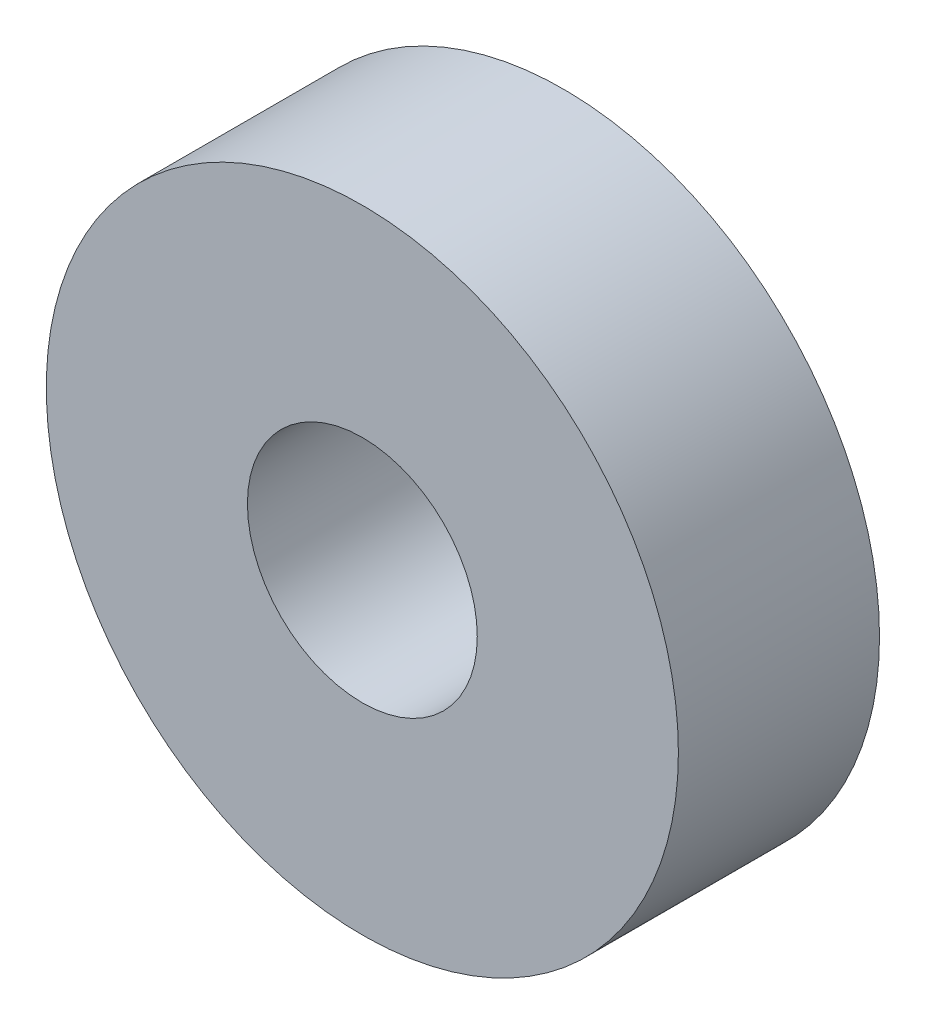
from build123d import *

# Parameters (mm, degrees)
ESQUISSE1_R      = 11
ESQUISSE1_R_2    = 4
EXTRUSION1_DEPTH = 7


with BuildPart() as part:
    # Esquisse1 → Extrusion1 (new body)
    with BuildSketch(Plane.XY):
        Circle(ESQUISSE1_R)
        Circle(ESQUISSE1_R_2, mode=Mode.SUBTRACT)
    extrude(amount=EXTRUSION1_DEPTH)


solid = part.part
